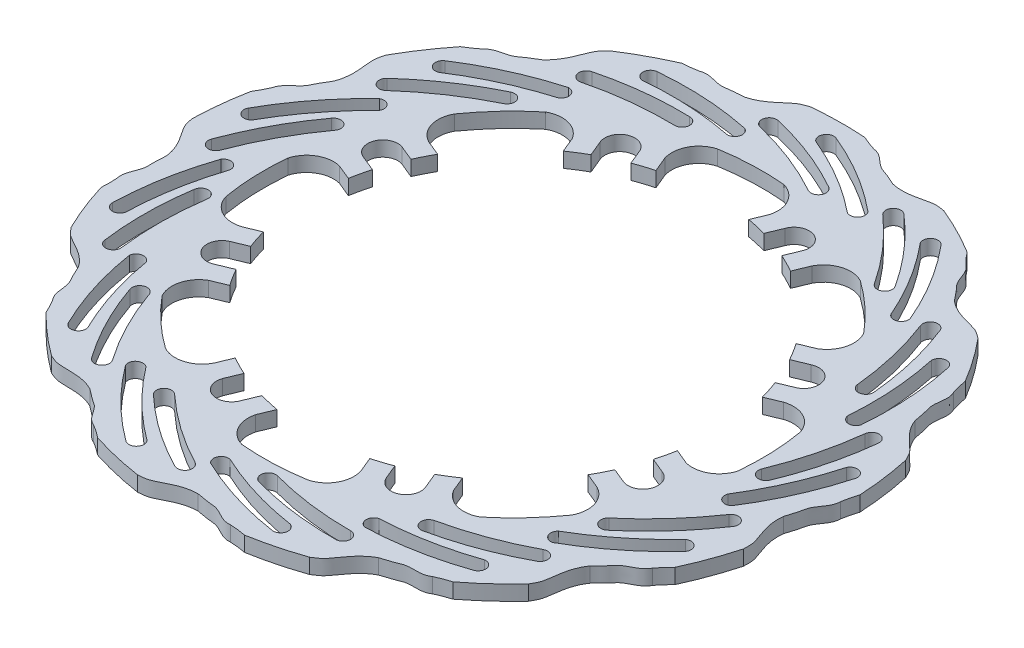
from build123d import *

# Parameters (mm, degrees)
DODANIE_WYCI_GNI_CIE1_DEPTH = 5


with BuildPart() as part:
    # Szkic1 → Dodanie-wyciągnięcie1 (new body)
    with BuildSketch(Plane(origin=(0, 5, 0), x_dir=(1, 0, 0), z_dir=(0, 1, 0))):
        with BuildLine():
            ThreePointArc((-44.33056104, 100.671750545), (-52.33496118, 96.752528847), (-59.995807298, 92.198173012))
            add(Edge.make_bspline(
                [(-68.572139541, 78.428630602), (-65.564762611, 81.08352124), (-64.12344414, 85.146306095), (-61.992463701, 90.244167691), (-60.593093092, 91.477422751), (-59.995807298, 92.198173012)],
                knots=[0, 0, 0, 0, 0.594179418, 0.740322373, 0.894848315, 0.894848315, 0.894848315, 0.894848315], degree=3))
            add(Edge.make_bspline(
                [(-81.665160628, 71.556883033), (-80.633695733, 72.700758004), (-78.180249198, 73.654460096), (-74.486469439, 74.256653816), (-71.726919984, 76.658004571), (-69.68806926, 77.615735473), (-68.572139541, 78.428630602)],
                knots=[0, 0, 0, 0, 0.147284023, 0.282720942, 0.381948392, 0.523861625, 0.523861625, 0.523861625, 0.523861625], degree=3))
            add(Edge.make_bspline(
                [(-81.665160628, 71.556883033), (-83.654073975, 69.933115953), (-86.037257642, 68.538969189)],
                knots=[0, 0, 0, 0.254896859, 0.254896859, 0.254896859], degree=2))
            ThreePointArc((-86.037257642, 68.538969189), (-91.303448838, 61.348840497), (-95.970276504, 53.75598597))
            add(Edge.make_bspline(
                [(-97.165216141, 37.578041349), (-95.736105316, 41.326428008), (-96.347951456, 45.59365943), (-96.830156397, 51.097907688), (-96.164197462, 52.84022076), (-95.970276504, 53.75598597)],
                knots=[0, 0, 0, 0, 0.594179418, 0.740322373, 0.894848315, 0.894848315, 0.894848315, 0.894848315], degree=3))
            add(Edge.make_bspline(
                [(-105.565050229, 25.408780766), (-105.183318627, 26.90097739), (-103.454107071, 28.88561211), (-100.463280901, 31.135413214), (-99.135784548, 34.544130285), (-97.775551632, 36.33966006), (-97.165216141, 37.578041349)],
                knots=[0, 0, 0, 0, 0.147284023, 0.282720942, 0.381948392, 0.523861625, 0.523861625, 0.523861625, 0.523861625], degree=3))
            add(Edge.make_bspline(
                [(-105.565050229, 25.408780766), (-106.571543349, 23.046712301), (-108.03385538, 20.704735975)],
                knots=[0, 0, 0, 0.254896859, 0.254896859, 0.254896859], degree=2))
            ThreePointArc((-108.03385538, 20.704735975), (-109.355416693, 11.890872122), (-109.959111931, 2.998950373))
            add(Edge.make_bspline(
                [(-103.498912691, -11.881224313), (-103.975460038, -7.898051843), (-106.500304211, -4.403945146), (-109.485227192, 0.24573283), (-109.705243098, 2.097960987), (-109.959111931, 2.998950373)],
                knots=[0, 0, 0, 0, 0.594179418, 0.740322373, 0.894848315, 0.894848315, 0.894848315, 0.894848315], degree=3))
            add(Edge.make_bspline(
                [(-105.281259019, -26.560166966), (-105.63671082, -25.061492953), (-105.027875771, -22.500581502), (-103.425165422, -19.118575332), (-103.833835588, -15.483387946), (-103.463833448, -13.261393532), (-103.498912691, -11.881224313)],
                knots=[0, 0, 0, 0, 0.147284023, 0.282720942, 0.381948392, 0.523861625, 0.523861625, 0.523861625, 0.523861625], degree=3))
            add(Edge.make_bspline(
                [(-105.281259019, -26.560166966), (-105.074756467, -29.119415396), (-105.281198799, -31.872702732)],
                knots=[0, 0, 0, 0.254896859, 0.254896859, 0.254896859], degree=2))
            ThreePointArc((-105.281198799, -31.872702732), (-102.35537646, -40.291151755), (-98.757639965, -48.445108613))
            add(Edge.make_bspline(
                [(-86.12225564, -58.618644669), (-88.395289905, -55.313183199), (-92.25472074, -53.392658963), (-97.058551878, -50.662736458), (-98.114139632, -49.124916365), (-98.757639965, -48.445108613)],
                knots=[0, 0, 0, 0, 0.594179418, 0.740322373, 0.894848315, 0.894848315, 0.894848315, 0.894848315], degree=3))
            add(Edge.make_bspline(
                [(-80.878800145, -72.44450053), (-81.890005625, -71.282677283), (-82.541023854, -68.732163053), (-82.693590954, -64.992728674), (-84.744806228, -61.963848594), (-85.449797896, -59.824421683), (-86.12225564, -58.618644669)],
                knots=[0, 0, 0, 0, 0.147284023, 0.282720942, 0.381948392, 0.523861625, 0.523861625, 0.523861625, 0.523861625], degree=3))
            add(Edge.make_bspline(
                [(-80.878800145, -72.44450053), (-79.506609167, -74.614635953), (-78.40988835, -77.14848935)],
                knots=[0, 0, 0, 0.254896859, 0.254896859, 0.254896859], degree=2))
            ThreePointArc((-78.40988835, -77.14848935), (-71.906952995, -83.242958326), (-64.931982842, -88.790977043))
            add(Edge.make_bspline(
                [(-49.016027708, -91.927239962), (-52.564824134, -90.05673088), (-56.874692537, -90.149758063), (-62.39693201, -89.964983375), (-64.046269179, -89.093867397), (-64.931982842, -88.790977043)],
                knots=[0, 0, 0, 0, 0.594179418, 0.740322373, 0.894848315, 0.894848315, 0.894848315, 0.894848315], degree=3))
            add(Edge.make_bspline(
                [(-37.947982852, -101.732672074), (-39.383287022, -101.173859298), (-41.1450181, -99.21803436), (-43.017911364, -95.977831124), (-46.241763046, -94.249138275), (-47.860243427, -92.68239579), (-49.016027708, -91.927239962)],
                knots=[0, 0, 0, 0, 0.147284023, 0.282720942, 0.381948392, 0.523861625, 0.523861625, 0.523861625, 0.523861625], degree=3))
            add(Edge.make_bspline(
                [(-37.947982852, -101.732672074), (-35.724455865, -103.016542617), (-33.575817421, -104.750486799)],
                knots=[0, 0, 0, 0.254896859, 0.254896859, 0.254896859], degree=2))
            ThreePointArc((-33.575817421, -104.750486799), (-24.985513172, -107.124806331), (-16.231190965, -108.79590268))
            add(Edge.make_bspline(
                [(-0.680818535, -104.176412424), (-4.692390629, -104.169366818), (-8.465357688, -106.254634013), (-13.440926984, -108.657336797), (-15.306170299, -108.652487106), (-16.231190965, -108.79590268)],
                knots=[0, 0, 0, 0, 0.594179418, 0.740322373, 0.894848315, 0.894848315, 0.894848315, 0.894848315], degree=3))
            add(Edge.make_bspline(
                [(13.676259989, -107.715114458), (12.145668017, -107.887329424), (9.676815449, -106.974249703), (6.512653298, -104.975569122), (2.854710775, -104.943086202), (0.693516032, -104.307949964), (-0.680818535, -104.176412424)],
                knots=[0, 0, 0, 0, 0.147284023, 0.282720942, 0.381948392, 0.523861625, 0.523861625, 0.523861625, 0.523861625], degree=3))
            add(Edge.make_bspline(
                [(13.676259989, -107.715114458), (16.241739749, -107.818600851), (18.950068647, -108.355410102)],
                knots=[0, 0, 0, 0.254896859, 0.254896859, 0.254896859], degree=2))
            ThreePointArc((18.950068647, -108.355410102), (27.65980661, -106.4656522), (36.187971155, -103.876998145))
            add(Edge.make_bspline(
                [(47.810357959, -92.560024261), (44.25501302, -94.418056195), (41.883288589, -98.017853817), (38.594232434, -102.457603821), (36.940387737, -103.320131423), (36.187971155, -103.876998145)],
                knots=[0, 0, 0, 0, 0.594179418, 0.740322373, 0.894848315, 0.894848315, 0.894848315, 0.894848315], degree=3))
            add(Edge.make_bspline(
                [(62.167436484, -89.021322227), (60.892196885, -89.885112563), (58.281807198, -90.223953619), (54.551247575, -89.924669326), (51.297204761, -91.595837781), (49.088399326, -92.037809849), (47.810357959, -92.560024261)],
                knots=[0, 0, 0, 0, 0.147284023, 0.282720942, 0.381948392, 0.523861625, 0.523861625, 0.523861625, 0.523861625], degree=3))
            add(Edge.make_bspline(
                [(62.167436484, -89.021322227), (64.487148521, -87.920716985), (67.13472236, -87.137414775)],
                knots=[0, 0, 0, 0.254896859, 0.254896859, 0.254896859], degree=2))
            ThreePointArc((67.13472236, -87.137414775), (73.968598035, -81.416500199), (80.316905196, -75.161125189))
            add(Edge.make_bspline(
                [(85.348757623, -59.739250009), (83.064126517, -63.036706758), (82.636978198, -67.326364556), (81.787918312, -72.786068558), (80.724348123, -74.318378774), (80.316905196, -75.161125189)],
                knots=[0, 0, 0, 0, 0.594179418, 0.740322373, 0.894848315, 0.894848315, 0.894848315, 0.894848315], degree=3))
            add(Edge.make_bspline(
                [(96.416802478, -49.933817897), (95.689057276, -51.291299647), (93.535139289, -52.804437076), (90.092808446, -54.273111498), (87.988127335, -57.265086775), (86.237721914, -58.682916673), (85.348757623, -59.739250009)],
                knots=[0, 0, 0, 0, 0.147284023, 0.282720942, 0.381948392, 0.523861625, 0.523861625, 0.523861625, 0.523861625], degree=3))
            add(Edge.make_bspline(
                [(96.416802478, -49.933817897), (97.959328721, -47.881256418), (99.939620242, -45.957287842)],
                knots=[0, 0, 0, 0.254896859, 0.254896859, 0.254896859], degree=2))
            ThreePointArc((99.939620242, -45.957287842), (103.332075069, -37.715809178), (106.04620418, -29.226744242))
            add(Edge.make_bspline(
                [(103.334785479, -13.232933516), (102.84424966, -17.214407478), (104.459531986, -21.211216545), (106.244977756, -26.440122156), (106.015333187, -28.291181182), (106.04620418, -29.226744242)],
                knots=[0, 0, 0, 0, 0.594179418, 0.740322373, 0.894848315, 0.894848315, 0.894848315, 0.894848315], degree=3))
            add(Edge.make_bspline(
                [(108.578240974, 0.592922346), (108.564707825, -0.947268108), (107.36069819, -3.288060362), (104.995192639, -6.188237887), (104.522030308, -9.815594507), (103.631021689, -11.884474494), (103.334785479, -13.232933516)],
                knots=[0, 0, 0, 0, 0.147284023, 0.282720942, 0.381948392, 0.523861625, 0.523861625, 0.523861625, 0.523861625], degree=3))
            add(Edge.make_bspline(
                [(108.578240974, 0.592922346), (108.990207249, 3.127222963), (109.84955553, 5.751099889)],
                knots=[0, 0, 0, 0.254896859, 0.254896859, 0.254896859], degree=2))
            ThreePointArc((109.84955553, 5.751099889), (109.02341899, 14.625119201), (107.481595782, 23.40313159))
            add(Edge.make_bspline(
                [(97.648059301, 36.304888571), (99.063994614, 32.551505099), (102.351665869, 29.763165553), (106.362593187, 25.962937595), (107.019483042, 24.217185074), (107.481595782, 23.40313159)],
                knots=[0, 0, 0, 0, 0.594179418, 0.740322373, 0.894848315, 0.894848315, 0.894848315, 0.894848315], degree=3))
            add(Edge.make_bspline(
                [(95.865712972, 50.983831224), (96.569492157, 49.613771138), (96.591214972, 46.981571355), (95.844443527, 43.314286447), (97.111195764, 39.882532171), (97.283703284, 37.636557569), (97.648059301, 36.304888571)],
                knots=[0, 0, 0, 0, 0.147284023, 0.282720942, 0.381948392, 0.523861625, 0.523861625, 0.523861625, 0.523861625], degree=3))
            add(Edge.make_bspline(
                [(95.865712972, 50.983831224), (95.05274277, 53.419293251), (94.594281476, 56.141979944)],
                knots=[0, 0, 0, 0.254896859, 0.254896859, 0.254896859], degree=2))
            ThreePointArc((94.594281476, 56.141979944), (89.738811496, 63.615609022), (84.294249083, 70.671632014))
            add(Edge.make_bspline(
                [(69.591339524, 77.525698208), (72.589372252, 74.860260146), (76.796266574, 73.919165109), (82.113820327, 72.418201229), (83.506759056, 71.177686078), (84.294249083, 70.671632014)],
                knots=[0, 0, 0, 0, 0.594179418, 0.740322373, 0.894848315, 0.894848315, 0.894848315, 0.894848315], degree=3))
            add(Edge.make_bspline(
                [(61.191505435, 89.694958791), (62.451369624, 88.808893327), (63.693848455, 86.488291265), (64.736887454, 82.89402975), (67.453356588, 80.444051366), (68.649860852, 78.535507863), (69.591339524, 77.525698208)],
                knots=[0, 0, 0, 0, 0.147284023, 0.282720942, 0.381948392, 0.523861625, 0.523861625, 0.523861625, 0.523861625], degree=3))
            add(Edge.make_bspline(
                [(61.191505435, 89.694958791), (59.339840433, 91.473647227), (57.668597521, 93.671408978)],
                knots=[0, 0, 0, 0.254896859, 0.254896859, 0.254896859], degree=2))
            ThreePointArc((57.668597521, 93.671408978), (49.896123758, 98.032529468), (41.796105776, 101.750113228))
            add(Edge.make_bspline(
                [(25.592082528, 100.986304672), (29.485399503, 100.019431758), (33.647768101, 101.14117476), (39.053760809, 102.283327696), (40.863642936, 101.832236986), (41.796105776, 101.750113228)],
                knots=[0, 0, 0, 0, 0.594179418, 0.740322373, 0.894848315, 0.894848315, 0.894848315, 0.894848315], degree=3))
            add(Edge.make_bspline(
                [(12.499061441, 107.85805224), (14.026390931, 107.658968318), (16.20498885, 106.181585942), (18.798890629, 103.483749819), (22.342766318, 102.576807849), (24.28916262, 101.44291976), (25.592082528, 100.986304672)],
                knots=[0, 0, 0, 0, 0.147284023, 0.282720942, 0.381948392, 0.523861625, 0.523861625, 0.523861625, 0.523861625], degree=3))
            add(Edge.make_bspline(
                [(12.499061441, 107.85805224), (10.032895775, 108.572491), (7.531732855, 109.741847078)],
                knots=[0, 0, 0, 0.254896859, 0.254896859, 0.254896859], degree=2))
            ThreePointArc((7.531732855, 109.741847078), (-1.37716462, 109.991378833), (-10.277021667, 109.518869724))
            add(Edge.make_bspline(
                [(-24.270012156, 101.312165752), (-20.373322933, 102.265356918), (-17.209028544, 105.192960157), (-12.953044662, 108.716576436), (-11.14084132, 109.158249611), (-10.277021667, 109.518869724)],
                knots=[0, 0, 0, 0, 0.594179418, 0.740322373, 0.894848315, 0.894848315, 0.894848315, 0.894848315], degree=3))
            add(Edge.make_bspline(
                [(-39.0567669, 101.312165751), (-37.611864888, 101.845671099), (-34.996238409, 101.549958907), (-31.445705488, 100.366589918), (-27.886282455, 101.210453838), (-25.635890053, 101.11098126), (-24.270012156, 101.312165752)],
                knots=[0, 0, 0, 0, 0.147284023, 0.282720942, 0.381948392, 0.523861625, 0.523861625, 0.523861625, 0.523861625], degree=3))
            add(Edge.make_bspline(
                [(-39.0567669, 101.312165751), (-41.572464395, 100.798685526), (-44.33056104, 100.671750545)],
                knots=[0, 0, 0, 0.254896859, 0.254896859, 0.254896859], degree=2))
        make_face()
        with BuildLine():
            Line((58.771687407, -33.703876028), (63.802605845, -35.787750676))
            ThreePointArc((63.802605845, -35.787750676), (68.326099184, -41.179640431), (67.585630297, -48.178652714))
            ThreePointArc((67.585630297, -48.178652714), (60.812448897, -56.487574378), (53.024866014, -63.85423701))
            ThreePointArc((53.024866014, -63.85423701), (46.267915, -64.708900887), (40.847055093, -60.585660022))
            Line((40.847055093, -60.585660022), (38.766503345, -55.562763775))
            ThreePointArc((38.766503345, -55.562763775), (35.974586461, -57.409856549), (33.094838298, -59.116784233))
            Line((33.094838298, -59.116784233), (35.178985703, -64.148361163))
            ThreePointArc((35.178985703, -64.148361163), (32.761122857, -70.800518228), (26.108965793, -68.382655383))
            Line((26.108965793, -68.382655383), (24.023438045, -63.34774601))
            ThreePointArc((24.023438045, -63.34774601), (20.899491624, -64.445897851), (17.725619416, -65.390097999))
            Line((17.725619416, -65.390097999), (19.809494064, -70.421016437))
            ThreePointArc((19.809494064, -70.421016437), (19.19544507, -77.432251061), (13.722805452, -81.857709536))
            ThreePointArc((13.722805452, -81.857709536), (3.0581481, -82.943641891), (-7.657521667, -82.646006328))
            ThreePointArc((-7.657521667, -82.646006328), (-13.039746172, -78.472459068), (-13.957301396, -71.723760692))
            Line((-13.957301396, -71.723760692), (-11.876749649, -66.700864446))
            ThreePointArc((-11.876749649, -66.700864446), (-15.157024836, -66.03277291), (-18.40029443, -65.203463596))
            Line((-18.40029443, -65.203463596), (-20.484441835, -70.235040526))
            ThreePointArc((-20.484441835, -70.235040526), (-26.897914419, -73.229138682), (-29.892012575, -66.815666099))
            Line((-29.892012575, -66.815666099), (-27.806484827, -61.780756725))
            ThreePointArc((-27.806484827, -61.780756725), (-30.79195914, -60.348303641), (-33.703876028, -58.771687407))
            Line((-33.703876028, -58.771687407), (-35.787750676, -63.802605845))
            ThreePointArc((-35.787750676, -63.802605845), (-41.179640431, -68.326099184), (-48.178652714, -67.585630297))
            ThreePointArc((-48.178652714, -67.585630297), (-56.487574378, -60.812448897), (-63.85423701, -53.024866014))
            ThreePointArc((-63.85423701, -53.024866014), (-64.708900887, -46.267915), (-60.585660022, -40.847055093))
            Line((-60.585660022, -40.847055093), (-55.562763776, -38.766503345))
            ThreePointArc((-55.562763776, -38.766503345), (-57.409856549, -35.974586461), (-59.116784233, -33.094838298))
            Line((-59.116784233, -33.094838298), (-64.148361163, -35.178985703))
            ThreePointArc((-64.148361163, -35.178985703), (-70.800518228, -32.761122857), (-68.382655383, -26.108965793))
            Line((-68.382655383, -26.108965793), (-63.34774601, -24.023438045))
            ThreePointArc((-63.34774601, -24.023438045), (-64.445897851, -20.899491624), (-65.390097999, -17.725619416))
            Line((-65.390097999, -17.725619416), (-70.421016437, -19.809494064))
            ThreePointArc((-70.421016437, -19.809494064), (-77.432251061, -19.19544507), (-81.857709536, -13.722805452))
            ThreePointArc((-81.857709536, -13.722805452), (-82.943641891, -3.0581481), (-82.646006328, 7.657521667))
            ThreePointArc((-82.646006328, 7.657521667), (-78.472459068, 13.039746172), (-71.723760692, 13.957301396))
            Line((-71.723760692, 13.957301396), (-66.700864446, 11.876749649))
            ThreePointArc((-66.700864446, 11.876749649), (-66.03277291, 15.157024836), (-65.203463596, 18.40029443))
            Line((-65.203463596, 18.40029443), (-70.235040526, 20.484441835))
            ThreePointArc((-70.235040526, 20.484441835), (-73.229138682, 26.897914419), (-66.815666099, 29.892012575))
            Line((-66.815666099, 29.892012575), (-61.780756725, 27.806484827))
            ThreePointArc((-61.780756725, 27.806484827), (-60.348303641, 30.79195914), (-58.771687407, 33.703876028))
            Line((-58.771687407, 33.703876028), (-63.802605845, 35.787750676))
            ThreePointArc((-63.802605845, 35.787750676), (-68.326099184, 41.179640431), (-67.585630297, 48.178652714))
            ThreePointArc((-67.585630297, 48.178652714), (-60.812448897, 56.487574378), (-53.024866014, 63.85423701))
            ThreePointArc((-53.024866014, 63.85423701), (-46.267915, 64.708900887), (-40.847055093, 60.585660022))
            Line((-40.847055093, 60.585660022), (-38.766503345, 55.562763776))
            ThreePointArc((-38.766503345, 55.562763776), (-35.974586461, 57.409856549), (-33.094838298, 59.116784233))
            Line((-33.094838298, 59.116784233), (-35.178985703, 64.148361163))
            ThreePointArc((-35.178985703, 64.148361163), (-32.761122857, 70.800518228), (-26.108965793, 68.382655383))
            Line((-26.108965793, 68.382655383), (-24.023438045, 63.34774601))
            ThreePointArc((-24.023438045, 63.34774601), (-20.899491624, 64.445897851), (-17.725619416, 65.390097999))
            Line((-17.725619416, 65.390097999), (-19.809494064, 70.421016437))
            ThreePointArc((-19.809494064, 70.421016437), (-19.19544507, 77.432251061), (-13.722805452, 81.857709536))
            ThreePointArc((-13.722805452, 81.857709536), (-3.0581481, 82.943641891), (7.657521667, 82.646006328))
            ThreePointArc((7.657521667, 82.646006328), (13.039746172, 78.472459068), (13.957301396, 71.723760692))
            Line((13.957301396, 71.723760692), (11.876749649, 66.700864446))
            ThreePointArc((11.876749649, 66.700864446), (15.157024836, 66.03277291), (18.40029443, 65.203463596))
            Line((18.40029443, 65.203463596), (20.484441835, 70.235040526))
            ThreePointArc((20.484441835, 70.235040526), (26.897914419, 73.229138682), (29.892012575, 66.815666099))
            Line((29.892012575, 66.815666099), (27.806484827, 61.780756725))
            ThreePointArc((27.806484827, 61.780756725), (30.79195914, 60.348303641), (33.703876028, 58.771687407))
            Line((33.703876028, 58.771687407), (35.787750676, 63.802605845))
            ThreePointArc((35.787750676, 63.802605845), (41.179640431, 68.326099184), (48.178652714, 67.585630297))
            ThreePointArc((48.178652714, 67.585630297), (56.487574378, 60.812448897), (63.85423701, 53.024866014))
            ThreePointArc((63.85423701, 53.024866014), (64.708900887, 46.267915), (60.585660022, 40.847055093))
            Line((60.585660022, 40.847055093), (55.562763775, 38.766503345))
            ThreePointArc((55.562763775, 38.766503345), (57.409856549, 35.974586461), (59.116784233, 33.094838298))
            Line((59.116784233, 33.094838298), (64.148361163, 35.178985703))
            ThreePointArc((64.148361163, 35.178985703), (70.800518228, 32.761122857), (68.382655383, 26.108965793))
            Line((68.382655383, 26.108965793), (63.34774601, 24.023438045))
            ThreePointArc((63.34774601, 24.023438045), (64.445897851, 20.899491624), (65.390097999, 17.725619416))
            Line((65.390097999, 17.725619416), (70.421016437, 19.809494064))
            ThreePointArc((70.421016437, 19.809494064), (77.432251061, 19.19544507), (81.857709536, 13.722805452))
            ThreePointArc((81.857709536, 13.722805452), (82.943641891, 3.0581481), (82.646006328, -7.657521667))
            ThreePointArc((82.646006328, -7.657521667), (78.472459068, -13.039746172), (71.723760692, -13.957301396))
            Line((71.723760692, -13.957301396), (66.700864446, -11.876749649))
            ThreePointArc((66.700864446, -11.876749649), (66.03277291, -15.157024836), (65.203463596, -18.40029443))
            Line((65.203463596, -18.40029443), (70.235040526, -20.484441835))
            ThreePointArc((70.235040526, -20.484441835), (73.229138682, -26.897914419), (66.815666099, -29.892012575))
            Line((66.815666099, -29.892012575), (61.780756725, -27.806484827))
            ThreePointArc((61.780756725, -27.806484827), (60.348303641, -30.79195914), (58.771687407, -33.703876028))
        make_face(mode=Mode.SUBTRACT)
        with BuildLine():
            ThreePointArc((-55.708806295, 78.380162857), (-58.741136729, 80.186275981), (-56.94544789, 83.224791091))
            ThreePointArc((-56.94544789, 83.224791091), (-42.391347521, 85.911366949), (-27.603739024, 86.516480458))
            ThreePointArc((-27.603739024, 86.516480458), (-25.103739024, 84.016480458), (-27.603739024, 81.516480458))
            ThreePointArc((-27.603739024, 81.516480458), (-41.762565171, 80.900826653), (-55.708806295, 78.380162857))
        make_face(mode=Mode.SUBTRACT)
        with BuildLine():
            ThreePointArc((-46.082567818, 89.139538614), (-48.319813439, 91.64170199), (-46.050715591, 94.115016463))
            ThreePointArc((-46.050715591, 94.115016463), (-30.49022696, 94.385978492), (-15.064222421, 92.326704157))
            ThreePointArc((-15.064222421, 92.326704157), (-13.713686803, 89.535865408), (-16.117106722, 87.577217896))
            ThreePointArc((-16.117106722, 87.577217896), (-31.043566739, 89.437652441), (-46.082567818, 89.139538614))
        make_face(mode=Mode.SUBTRACT)
        with BuildLine():
            ThreePointArc((15.764316183, 89.434636099), (16.816148317, 86.059188105), (13.440700323, 85.007355971))
            ThreePointArc((13.440700323, 85.007355971), (0.617573806, 91.042156199), (-12.902620308, 95.291360666))
            ThreePointArc((-12.902620308, 95.291360666), (-14.748272942, 98.299788633), (-11.746201059, 100.155761932))
            ThreePointArc((-11.746201059, 100.155761932), (2.389328865, 95.770979024), (15.764316183, 89.434636099))
        make_face(mode=Mode.SUBTRACT)
        with BuildLine():
            ThreePointArc((0.621121787, 100.344778683), (14.076036316, 93.61977308), (26.428173237, 85.035768256))
            ThreePointArc((26.428173237, 85.035768256), (29.46652477, 85.653139569), (29.567652306, 88.751929752))
            ThreePointArc((29.567652306, 88.751929752), (16.865596136, 97.744148382), (2.961545382, 104.735543056))
            ThreePointArc((2.961545382, 104.735543056), (-0.197047528, 103.600034202), (0.621121787, 100.344778683))
        make_face(mode=Mode.SUBTRACT)
        with BuildLine():
            ThreePointArc((55.520956533, 71.864394415), (54.883658735, 68.386772883), (51.406037204, 69.024070681))
            ThreePointArc((51.406037204, 69.024070681), (42.856234066, 80.326824937), (32.859400499, 90.372456131))
            ThreePointArc((32.859400499, 90.372456131), (32.62324244, 93.894004349), (36.143958877, 94.142254722))
            ThreePointArc((36.143958877, 94.142254722), (46.622638803, 83.69061397), (55.520956533, 71.864394415))
        make_face(mode=Mode.SUBTRACT)
        with BuildLine():
            ThreePointArc((47.182519876, 88.56223924), (55.970989085, 76.354731948), (62.919077201, 63.0136489))
            ThreePointArc((62.919077201, 63.0136489), (65.896310629, 62.148311687), (67.425934218, 64.845157818))
            ThreePointArc((67.425934218, 64.845157818), (60.35771441, 78.710311823), (51.295351999, 91.362418935))
            ThreePointArc((51.295351999, 91.362418935), (47.970859598, 91.824847095), (47.182519876, 88.56223924))
        make_face(mode=Mode.SUBTRACT)
        with BuildLine():
            ThreePointArc((82.558414842, 37.830886029), (80.377984357, 35.047772143), (77.594870471, 37.228202628))
            ThreePointArc((77.594870471, 37.228202628), (75.277047576, 51.209586125), (71.09372865, 64.750311003))
            ThreePointArc((71.09372865, 64.750311003), (72.521166132, 67.978235215), (75.753973416, 66.561891493))
            ThreePointArc((75.753973416, 66.561891493), (80.175264054, 52.437737837), (82.558414842, 37.830886029))
        make_face(mode=Mode.SUBTRACT)
        with BuildLine():
            ThreePointArc((82.934971273, 56.491158079), (85.043662779, 41.5977419), (84.995978835, 26.555861978))
            ThreePointArc((84.995978835, 26.555861978), (87.230045859, 24.406054566), (89.837747171, 26.083141696))
            ThreePointArc((89.837747171, 26.083141696), (90.022607702, 41.644891387), (87.878011648, 57.059265672))
            ThreePointArc((87.878011648, 57.059265672), (85.149220901, 59.013694127), (82.934971273, 56.491158079))
        make_face(mode=Mode.SUBTRACT)
        with BuildLine():
            ThreePointArc((90.682735247, -4.869222434), (87.458682422, -6.320250823), (86.007654033, -3.096197998))
            ThreePointArc((86.007654033, -3.096197998), (90.452796672, 10.360848274), (93.041340339, 24.29464995))
            ThreePointArc((93.041340339, 24.29464995), (95.805364638, 26.489471619), (98.009665581, 23.73300108))
            ThreePointArc((98.009665581, 23.73300108), (95.360702528, 9.172007909), (90.682735247, -4.869222434))
        make_face(mode=Mode.SUBTRACT)
        with BuildLine():
            ThreePointArc((99.688020226, 11.478633394), (94.633858217, -2.68878951), (87.601326031, -15.98555289))
            ThreePointArc((87.601326031, -15.98555289), (88.580428819, -18.927335531), (91.66881491, -18.654207852))
            ThreePointArc((91.66881491, -18.654207852), (99.064406459, -4.960871791), (104.328877874, 9.684522283))
            ThreePointArc((104.328877874, 9.684522283), (102.820921855, 12.683215026), (99.688020226, 11.478633394))
        make_face(mode=Mode.SUBTRACT)
        with BuildLine():
            ThreePointArc((78.032733852, -46.453850718), (74.503650336, -46.240380493), (74.717120561, -42.711296977))
            ThreePointArc((74.717120561, -42.711296977), (84.906900126, -32.861435055), (93.674302227, -21.726622624))
            ThreePointArc((93.674302227, -21.726622624), (97.141708685, -21.067710692), (97.812524505, -24.532833866))
            ThreePointArc((97.812524505, -24.532833866), (88.700153273, -36.194918497), (78.032733852, -46.453850718))
        make_face(mode=Mode.SUBTRACT)
        with BuildLine():
            ThreePointArc((93.603745116, -36.16350787), (82.544577199, -46.359351646), (70.138265143, -54.864870238))
            ThreePointArc((70.138265143, -54.864870238), (69.638103046, -57.924701157), (72.499661882, -59.118103189))
            ThreePointArc((72.499661882, -59.118103189), (85.411743552, -50.430159026), (96.879255478, -39.908828451))
            ThreePointArc((96.879255478, -39.908828451), (96.937588738, -36.552835787), (93.603745116, -36.16350787))
        make_face(mode=Mode.SUBTRACT)
        with BuildLine():
            ThreePointArc((47.506373528, -77.396461632), (44.480729824, -75.567396249), (46.309795207, -72.541752545))
            ThreePointArc((46.309795207, -72.541752545), (59.909855999, -68.555559636), (72.847610372, -62.770587789))
            ThreePointArc((72.847610372, -62.770587789), (76.224057957, -63.798534376), (75.207712834, -67.178492227))
            ThreePointArc((75.207712834, -67.178492227), (61.719467856, -73.270025271), (47.506373528, -77.396461632))
        make_face(mode=Mode.SUBTRACT)
        with BuildLine():
            ThreePointArc((66.075980047, -75.521025297), (51.545328315, -79.409545011), (36.607372969, -81.175307008))
            ThreePointArc((36.607372969, -81.175307008), (34.742527096, -83.652215817), (36.721710032, -86.038753535))
            ThreePointArc((36.721710032, -86.038753535), (52.192279521, -84.346504577), (67.235763174, -80.35954754))
            ThreePointArc((67.235763174, -80.35954754), (68.847022267, -77.415072431), (66.075980047, -75.521025297))
        make_face(mode=Mode.SUBTRACT)
        with BuildLine():
            ThreePointArc((6.096875543, -90.608475914), (4.26781016, -87.58283221), (7.293453865, -85.753766827))
            ThreePointArc((7.293453865, -85.753766827), (21.188185856, -88.544431688), (35.33240889, -89.43456776))
            ThreePointArc((35.33240889, -89.43456776), (37.844394151, -91.913882691), (35.373720504, -94.434367607))
            ThreePointArc((35.373720504, -94.434367607), (20.599596154, -93.559852255), (6.096875543, -90.608475914))
        make_face(mode=Mode.SUBTRACT)
        with BuildLine():
            ThreePointArc((23.411004252, -97.577585956), (8.737665902, -94.267968603), (-5.309827185, -88.889459211))
            ThreePointArc((-5.309827185, -88.889459211), (-8.11214312, -90.216015951), (-7.468743041, -93.248962326))
            ThreePointArc((-7.468743041, -93.248962326), (7.016193236, -98.940082416), (22.189367805, -102.400862725))
            ThreePointArc((22.189367805, -102.400862725), (24.98443269, -100.542448934), (23.411004252, -97.577585956))
        make_face(mode=Mode.SUBTRACT)
        with BuildLine():
            ThreePointArc((-36.709343154, -83.063180316), (-36.922813378, -79.5340968), (-33.393729862, -79.320626575))
            ThreePointArc((-33.393729862, -79.320626575), (-22.387442322, -88.248841517), (-10.277021667, -95.61016606))
            ThreePointArc((-10.277021667, -95.61016606), (-9.204964281, -98.972868164), (-12.563964894, -100.056467425))
            ThreePointArc((-12.563964894, -100.056467425), (-25.239394776, -92.416244606), (-36.709343154, -83.063180316))
        make_face(mode=Mode.SUBTRACT)
        with BuildLine():
            ThreePointArc((-24.617150485, -97.28029761), (-36.071690468, -87.53073664), (-46.010609922, -76.240107543))
            ThreePointArc((-46.010609922, -76.240107543), (-49.108419108, -76.112414051), (-49.948197092, -79.09695762))
            ThreePointArc((-49.948197092, -79.09695762), (-39.767218364, -90.86767973), (-27.940344317, -100.983374324))
            ThreePointArc((-27.940344317, -100.983374324), (-24.601789321, -100.636762054), (-24.617150485, -97.28029761))
        make_face(mode=Mode.SUBTRACT)
        with BuildLine():
            ThreePointArc((-71.105893729, -56.489111127), (-69.65486534, -53.265058302), (-66.430812516, -54.716086691))
            ThreePointArc((-66.430812516, -54.716086691), (-60.834377262, -67.736505268), (-53.532110412, -79.882627543))
            ThreePointArc((-53.532110412, -79.882627543), (-54.145576328, -83.358362293), (-57.623397347, -82.756836368))
            ThreePointArc((-57.623397347, -82.756836368), (-65.296344529, -70.101189054), (-71.105893729, -56.489111127))
        make_face(mode=Mode.SUBTRACT)
        with BuildLine():
            ThreePointArc((-67.005812714, -74.697265436), (-72.617457263, -60.741267773), (-76.170916414, -46.125066029))
            ThreePointArc((-76.170916414, -46.125066029), (-78.854548099, -44.572375347), (-80.98512113, -46.824793145))
            ThreePointArc((-80.98512113, -46.824793145), (-77.440439485, -61.978586693), (-71.669260274, -76.431811847))
            ThreePointArc((-71.669260274, -76.431811847), (-68.552037882, -77.676405792), (-67.005812714, -74.697265436))
        make_face(mode=Mode.SUBTRACT)
        with BuildLine():
            ThreePointArc((-89.212940971, -16.974067346), (-86.429827085, -14.793636861), (-84.2493966, -17.576750747))
            ThreePointArc((-84.2493966, -17.576750747), (-85.344889505, -31.706551976), (-84.523637793, -45.854941746))
            ThreePointArc((-84.523637793, -45.854941746), (-86.682089363, -48.647460197), (-89.482003905, -46.498611427))
            ThreePointArc((-89.482003905, -46.498611427), (-90.394688658, -31.726795901), (-89.212940971, -16.974067346))
        make_face(mode=Mode.SUBTRACT)
        with BuildLine():
            ThreePointArc((-94.044250758, -35.001989951), (-92.527439734, -20.03670647), (-88.881383914, -5.443327756))
            ThreePointArc((-88.881383914, -5.443327756), (-90.536050421, -2.821342606), (-93.469329894, -3.82563286))
            ThreePointArc((-93.469329894, -3.82563286), (-97.372989178, -18.890946367), (-98.97961241, -34.370642379))
            ThreePointArc((-98.97961241, -34.370642379), (-96.797840706, -36.921321065), (-94.044250758, -35.001989951))
        make_face(mode=Mode.SUBTRACT)
        with BuildLine():
            ThreePointArc((-86.882378568, 26.429530704), (-83.404757037, 27.066828502), (-82.767459239, 23.589206971))
            ThreePointArc((-82.767459239, 23.589206971), (-90.30391608, 11.586990269), (-96.151818376, -1.322441407))
            ThreePointArc((-96.151818376, -1.322441407), (-99.360780358, -2.792011236), (-100.841361743, 0.411885023))
            ThreePointArc((-100.841361743, 0.411885023), (-94.784698989, 13.915823844), (-86.882378568, 26.429530704))
        make_face(mode=Mode.SUBTRACT)
        with BuildLine():
            ThreePointArc((-99.538284309, 12.711819613), (-91.240500839, 25.258022816), (-81.230197496, 36.485411307))
            ThreePointArc((-81.230197496, 36.485411307), (-81.47683467, 39.576025725), (-84.540841606, 40.049933809))
            ThreePointArc((-84.540841606, 40.049933809), (-94.998560522, 28.524382111), (-103.614928177, 15.564427047))
            ThreePointArc((-103.614928177, 15.564427047), (-102.868424764, 12.291993368), (-99.538284309, 12.711819613))
        make_face(mode=Mode.SUBTRACT)
        with BuildLine():
            ThreePointArc((-64.648110282, 63.77844178), (-61.272662288, 62.726609646), (-62.324494422, 59.351161652))
            ThreePointArc((-62.324494422, 59.351161652), (-74.575403761, 52.226092681), (-85.752776124, 43.513014321))
            ThreePointArc((-85.752776124, 43.513014321), (-89.277113999, 43.703053852), (-89.099178876, 47.228023578))
            ThreePointArc((-89.099178876, 47.228023578), (-77.460677061, 56.37049605), (-64.648110282, 63.77844178))
        make_face(mode=Mode.SUBTRACT)
        with BuildLine():
            ThreePointArc((-82.229296492, 57.513504498), (-69.051462769, 64.766443468), (-54.970151762, 70.055782336))
            ThreePointArc((-54.970151762, 70.055782336), (-53.752257997, 72.907003506), (-56.245065334, 74.750543297))
            ThreePointArc((-56.245065334, 74.750543297), (-70.861106507, 69.405118404), (-84.513312594, 61.933873808))
            ThreePointArc((-84.513312594, 61.933873808), (-85.373092409, 58.689360254), (-82.229296492, 57.513504498))
        make_face(mode=Mode.SUBTRACT)
    extrude(amount=-DODANIE_WYCI_GNI_CIE1_DEPTH)


solid = part.part
